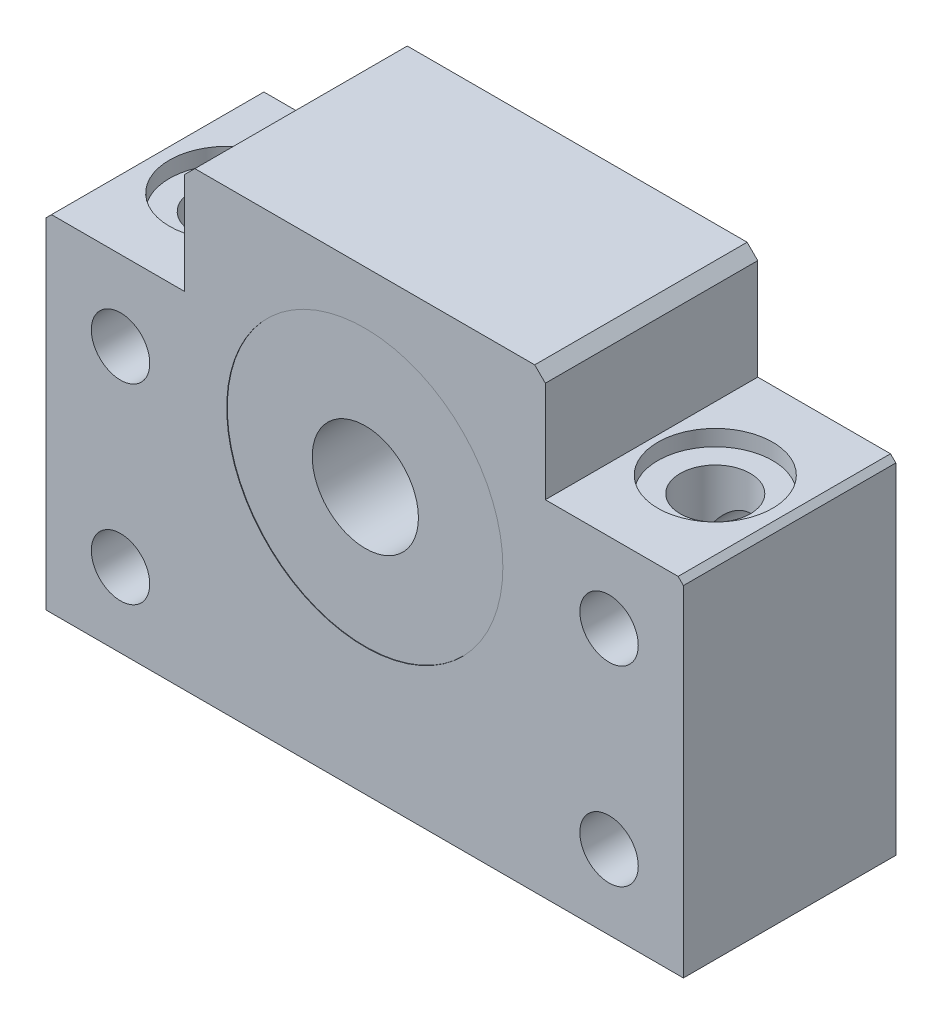
from build123d import *

# Parameters (mm, degrees)
EXTRUDE_1_DEPTH      = 10
EXTRUDE_1_DEPTH_BACK = 10
SKETCH_1_R           = 2.75
SKETCH_1_R_2         = 13
CUT_EXTRUDE_START    = 7.5
SKETCH_2_R           = 3.3
CUT_EXTRUDE_1_DEPTH  = 48.811288741
SKETCH_3_R           = 5.4
CUT_EXTRUDE_2_DEPTH  = 1.5
EXTRUDE_2_DEPTH      = 4
EXTRUDE_2_DEPTH_BACK = 4
EXTRUDE_2_START      = 5.95
SKETCH_4_R           = 13
SKETCH_4_R_2         = 5


with BuildPart() as part:
    # Эскиз1 → Бобышка-Вытянуть1 (new, two sides: drawn at the far end of the back side and taken through both)
    with BuildSketch(Plane.XY.offset(-EXTRUDE_1_DEPTH_BACK)):
        Polygon((-30, -25), (-30, 7), (-29.5, 7.5), (-17, 7.5), (-17, 17), (-16, 18), (16, 18), (17, 17), (17, 7.5), (29.5, 7.5), (30, 7), (30, -25), align=None)
        with Locations((-23, 0)):
            Circle(SKETCH_1_R, mode=Mode.SUBTRACT)
        with Locations((-23, -18)):
            Circle(SKETCH_1_R, mode=Mode.SUBTRACT)
        with Locations((23, -18)):
            Circle(SKETCH_1_R, mode=Mode.SUBTRACT)
        with Locations((23, 0)):
            Circle(SKETCH_1_R, mode=Mode.SUBTRACT)
        Circle(SKETCH_1_R_2, mode=Mode.SUBTRACT)
    extrude(amount=EXTRUDE_1_DEPTH + EXTRUDE_1_DEPTH_BACK)

    # Эскиз2 → Вырез-Вытянуть1 (cut, through all)
    with BuildSketch(Plane(origin=(0, 0, 0), x_dir=(1, 0, 0), z_dir=(0, 1, 0)).offset(CUT_EXTRUDE_START)):
        with Locations((-23, 0)):
            Circle(SKETCH_2_R)
        with Locations((23, 0)):
            Circle(SKETCH_2_R)
    extrude(amount=-CUT_EXTRUDE_1_DEPTH, mode=Mode.SUBTRACT)

    # Эскиз3 → Вырез-Вытянуть2 (cut)
    with BuildSketch(Plane(origin=(0, 0, 0), x_dir=(1, 0, 0), z_dir=(0, 1, 0)).offset(CUT_EXTRUDE_START)):
        with Locations((-23, 0)):
            Circle(SKETCH_3_R)
        with Locations((23, 0)):
            Circle(SKETCH_3_R)
    extrude(amount=-CUT_EXTRUDE_2_DEPTH, mode=Mode.SUBTRACT)

    # Эскиз4 → Бобышка-Вытянуть2 (add, two sides: drawn at the far end of the back side and taken through both)
    with BuildSketch(Plane.XY.offset(EXTRUDE_2_START - EXTRUDE_2_DEPTH_BACK)):
        Circle(SKETCH_4_R)
        Circle(SKETCH_4_R_2, mode=Mode.SUBTRACT)
    extrude(amount=EXTRUDE_2_DEPTH + EXTRUDE_2_DEPTH_BACK)


solid = part.part
